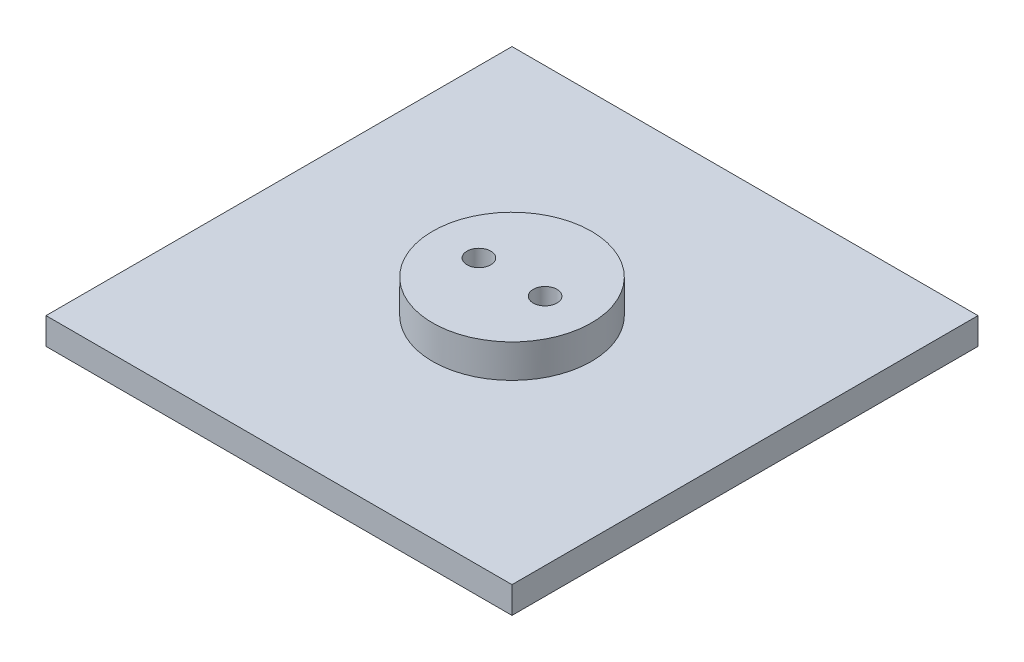
from build123d import *

# Parameters (mm, degrees)
SKETCH1_W           = 69.85
SKETCH1_H           = 69.85
BOSS_EXTRUDE1_DEPTH = 4
SKETCH2_R           = 11.90625
BOSS_EXTRUDE2_DEPTH = 5
SKETCH3_R           = 1.7859375
CUT_EXTRUDE1_DEPTH  = 9


with BuildPart() as part:
    # Sketch1 → Boss-Extrude1 (new body)
    with BuildSketch(Plane(origin=(0, 0, 0), x_dir=(1, 0, 0), z_dir=(0, 1, 0))):
        with Locations((34.925, 34.925)):
            Rectangle(SKETCH1_W, SKETCH1_H)
    extrude(amount=BOSS_EXTRUDE1_DEPTH)

    # Sketch2 → Boss-Extrude2 (add)
    with BuildSketch(Plane(origin=(0, 4, 0), x_dir=(1, 0, 0), z_dir=(0, 1, 0))):
        with Locations((34.925, 34.925)):
            Circle(SKETCH2_R)
    extrude(amount=BOSS_EXTRUDE2_DEPTH)

    # Sketch3 → Cut-Extrude1 (cut)
    with BuildSketch(Plane(origin=(0, 9, 0), x_dir=(1, 0, 0), z_dir=(0, 1, 0))):
        with Locations((29.9640625, 34.925)):
            Circle(SKETCH3_R)
        with Locations((39.8859375, 34.925)):
            Circle(SKETCH3_R)
    extrude(amount=-CUT_EXTRUDE1_DEPTH, mode=Mode.SUBTRACT)


solid = part.part
